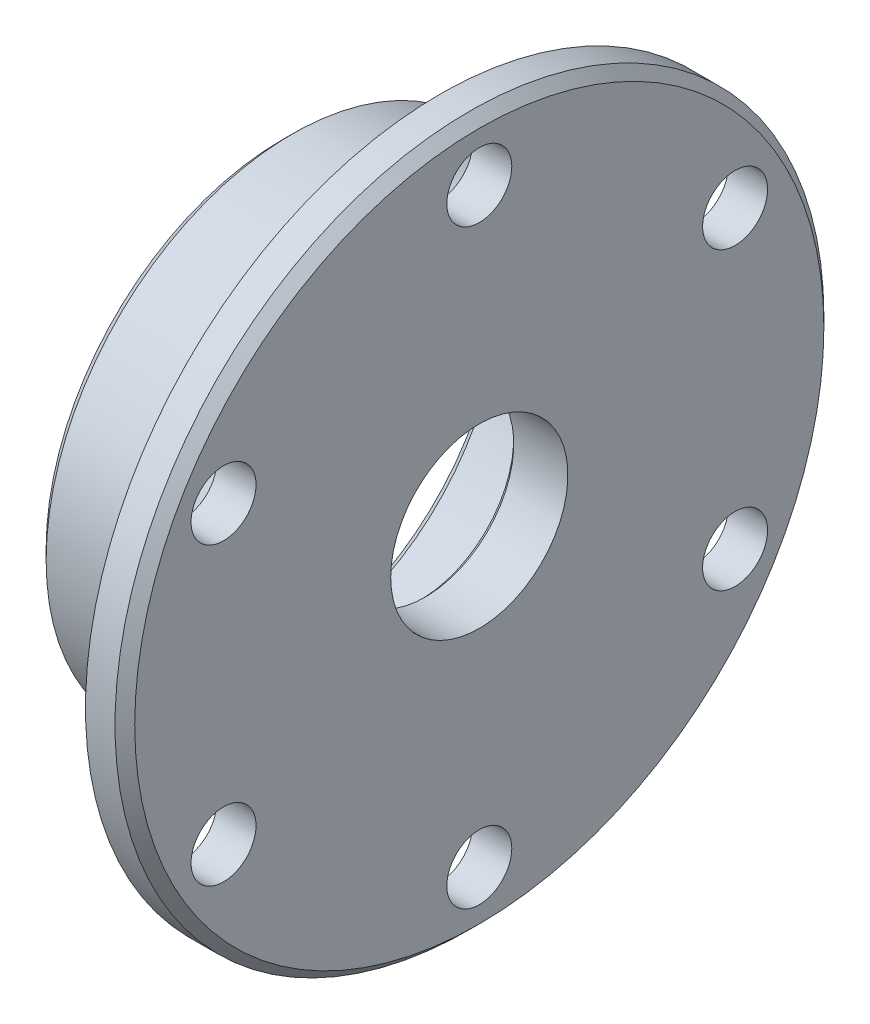
from build123d import *

# Parameters (mm, degrees)
SKETCH_2_W               = 20
SKETCH_2_H               = 9
CHAMFER_1_SIZE           = 1
FILLET_1_R               = 0.5
CHAMFER_2_SIZE           = 0.5
CHAMFER_3_SIZE           = 1
PATTERN_CIRCULAR_1_COUNT = 6


with BuildPart() as part:
    # Эскиз1 → Повернуть1 (revolve)
    with BuildSketch(Plane.XY):
        Polygon((0, 36), (0, 0), (-6, 0), (-6, 19), (-8, 19), (-8, 21), (-20, 21), (-20, 25), (-4, 25), (-4, 36), align=None)
    revolve(axis=Axis((0, 0, 0), (-1, 0, 0)))

    # Эскиз2 → Вырез-Повернуть1 (revolve, cut)
    with BuildSketch(Plane.XY):
        with Locations((-10, 4.5)):
            Rectangle(SKETCH_2_W, SKETCH_2_H)
    revolve(axis=Axis((0, 0, 0), (1, 0, 0)), mode=Mode.SUBTRACT)

    # Фаска1
    chamfer_1_edges = [part.edges().sort_by_distance(p)[0] for p in [
        (-20, -25, 0),
        (-20, -21, 0),
    ]]
    chamfer(chamfer_1_edges, length=CHAMFER_1_SIZE)

    # Скругление1
    fillet_1_edges = [part.edges().sort_by_distance(p)[0] for p in [
        (-6, -19, 0),
        (-4, -25, 0),
        (-8, -21, 0),
    ]]
    fillet(fillet_1_edges, radius=FILLET_1_R)

    # Фаска2
    chamfer_2_edges = [part.edges().sort_by_distance(p)[0] for p in [
        (-6, -9, 0),
    ]]
    chamfer(chamfer_2_edges, length=CHAMFER_2_SIZE)

    # Фаска3
    chamfer_3_edges = [part.edges().sort_by_distance(p)[0] for p in [
        (0, -36, 0),
    ]]
    chamfer(chamfer_3_edges, length=CHAMFER_3_SIZE)

    # Эскиз3 → Отверстие с зазором M61 (revolve, cut)
    with BuildSketch(Plane(origin=(0, -30, 0), x_dir=(0, 0, -1), z_dir=(0, 1, 0))):
        Polygon((0, 0), (0, 17.982840043), (3.3, 16), (3.3, 0), align=None)
    hole_wizard_m61 = revolve(axis=Axis((6.35, -30, 0), (-1, 0, 0)), mode=Mode.SUBTRACT)

    # Круговой массив1: Отверстие с зазором M61 ×6 about axis
    pattern_circular_1_axis = Axis((0, 0, 0), (1, 0, 0))
    for i in range(1, PATTERN_CIRCULAR_1_COUNT):
        add(hole_wizard_m61.rotate(pattern_circular_1_axis, i * 360 / PATTERN_CIRCULAR_1_COUNT), mode=Mode.SUBTRACT)


solid = part.part
